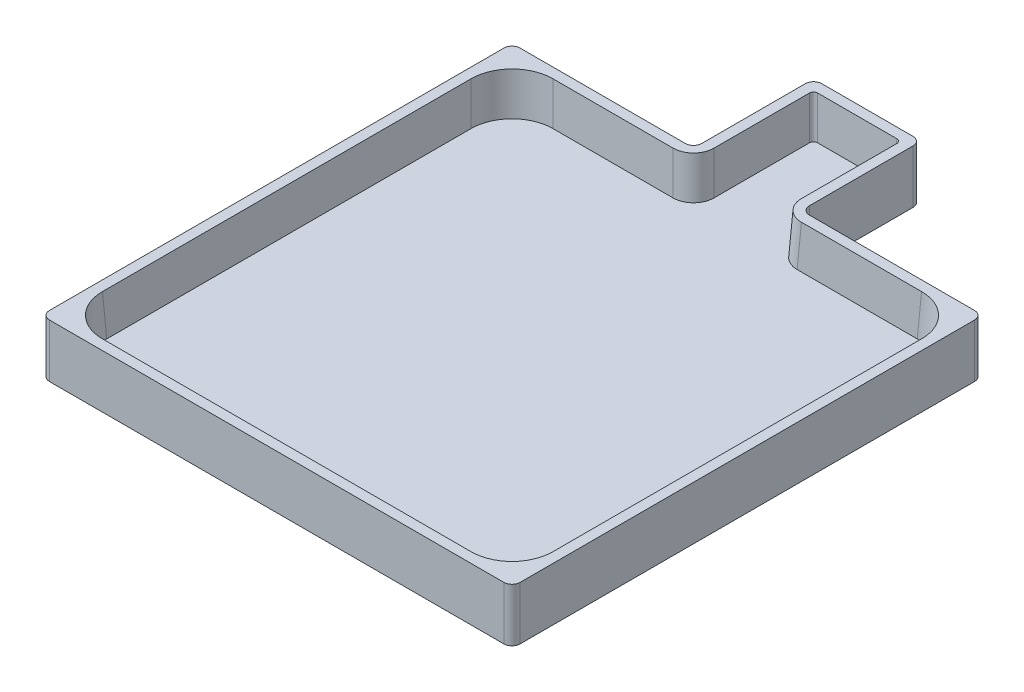
from build123d import *

# Parameters (mm, degrees)
BOSS_EXTRUDE3_DEPTH = 3
BOSS_EXTRUDE4_START = 3
BOSS_EXTRUDE4_DEPTH = 10
DRAFT12_ANGLE       = 3
FILLET1_R           = 2
FILLET3_R           = 10
FILLET4_R           = 5
FILLET5_R           = 1


with BuildPart() as part:
    # Sketch2 → Boss-Extrude3 (new body)
    with BuildSketch(Plane(origin=(0, 0, 0), x_dir=(1, 0, 0), z_dir=(0, 1, 0))):
        Polygon((-57.4, 57.4), (-57.4, -57.4), (57.4, -57.4), (57.4, 57.4), (13.13705704, 57.4), (13.13705704, 86.662771881), (-13.13705704, 86.662771881), (-13.13705704, 57.4), align=None)
    extrude(amount=BOSS_EXTRUDE3_DEPTH)

    # Sketch2_5 → Boss-Extrude4 (add)
    with BuildSketch(Plane(origin=(0, 0, 0), x_dir=(1, 0, 0), z_dir=(0, 1, 0)).offset(BOSS_EXTRUDE4_START)):
        Polygon((-57.4, 44.4), (-57.4, -44.4), (-57.4, -57.4), (-44.4, -57.4), (44.4, -57.4), (57.4, -57.4), (57.4, -44.4), (57.4, 44.4), (57.4, 57.4), (44.4, 57.4), (13.13705704, 57.4), (13.13705704, 86.662771881), (-13.13705704, 86.662771881), (-13.13705704, 57.4), (-44.4, 57.4), (-57.4, 57.4), align=None)
        Polygon((54.4, -44.4), (54.4, 44.4), (54.4, 54.4), (44.4, 54.4), (13.13705704, 54.4), (10.13705704, 54.4), (10.13705704, 57.4), (10.13705704, 83.662771881), (-10.13705704, 83.662771881), (-10.13705704, 57.4), (-10.13705704, 54.4), (-13.13705704, 54.4), (-44.4, 54.4), (-54.4, 54.4), (-54.4, 44.4), (-54.4, -44.4), (-54.4, -54.4), (-44.4, -54.4), (44.4, -54.4), (54.4, -54.4), align=None, mode=Mode.SUBTRACT)
    extrude(amount=BOSS_EXTRUDE4_DEPTH)

    # Draft12
    draft12_faces = [part.faces().sort_by_distance(p)[0] for p in [
        (-10.13705704, 8, -69.03138594),
        (-32.26852852, 8, -54.4),
        (-54.4, 8, 0),
        (0, 8, 54.4),
        (54.4, 8, 0),
        (0, 8, -83.662771881),
        (32.26852852, 8, -54.4),
        (10.13705704, 8, -69.03138594),
    ]]
    draft(draft12_faces, Plane.ZX.offset(3), DRAFT12_ANGLE)

    # Fillet1
    fillet1_edges = [part.edges().sort_by_distance(p)[0] for p in [
        (-57.4, 6.5, -57.4),
        (-13.13705704, 6.5, -57.4),
        (-13.13705704, 6.5, -86.662771881),
        (13.13705704, 6.5, -86.662771881),
        (13.13705704, 6.5, -57.4),
        (57.4, 6.5, -57.4),
        (57.4, 6.5, 57.4),
        (-57.4, 6.5, 57.4),
    ]]
    fillet(fillet1_edges, radius=FILLET1_R)

    # Fillet3
    fillet3_edges = [part.edges().sort_by_distance(p)[0] for p in [
        (-54.662038896, 8, -54.662038896),
        (-54.662038896, 8, 54.662038896),
        (54.662038896, 8, 54.662038896),
        (54.662038896, 8, -54.662038896),
    ]]
    fillet(fillet3_edges, radius=FILLET3_R)

    # Fillet4
    fillet4_edges = [part.edges().sort_by_distance(p)[0] for p in [
        (10.399095937, 8, -54.662038896),
        (-10.399095937, 8, -54.662038896),
    ]]
    fillet(fillet4_edges, radius=FILLET4_R)

    # Fillet5
    fillet5_edges = [part.edges().sort_by_distance(p)[0] for p in [
        (10.399095937, 8, -83.924810777),
        (-10.399095937, 8, -83.924810777),
    ]]
    fillet(fillet5_edges, radius=FILLET5_R)


solid = part.part
